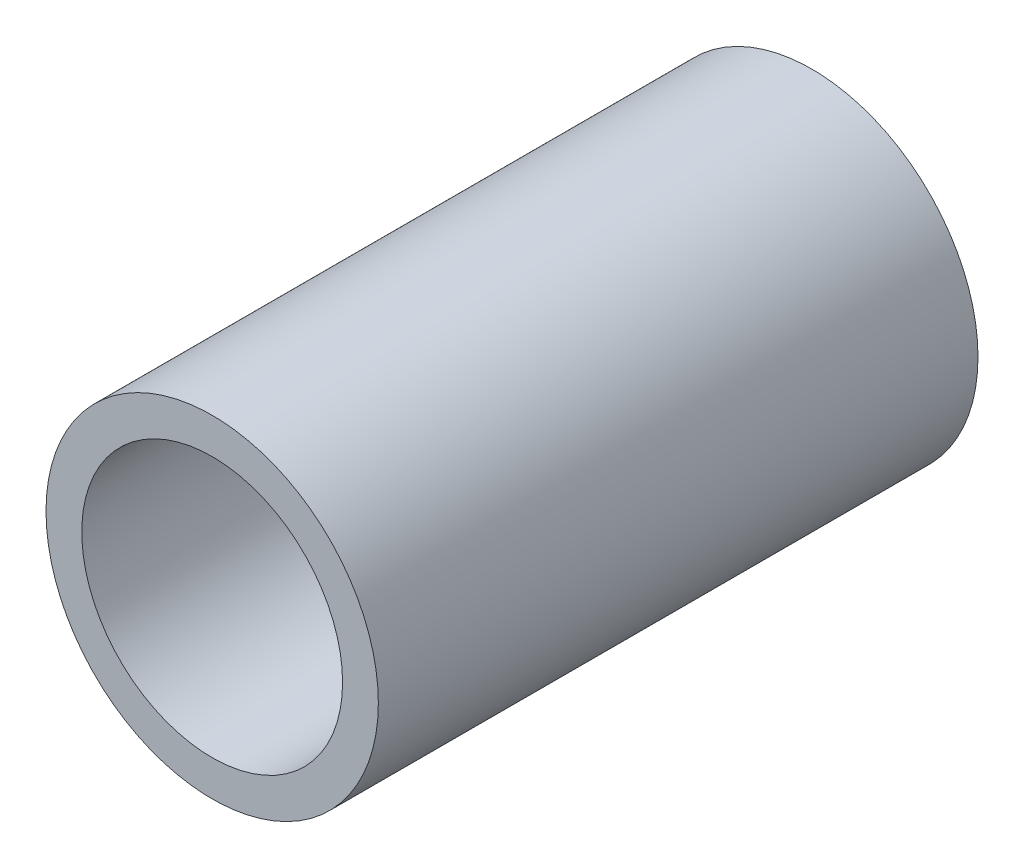
from build123d import *

# Parameters (mm, degrees)
SKETCH3_R                = 13.335
SKETCH3_R_2              = 10.4648
BOSS_EXTRUDE1_DEPTH      = 762
BOSS_EXTRUDE1_DEPTH_BACK = 762
SKETCH4_R                = 13.335
CUT_EXTRUDE2_DEPTH       = 1475.877934


with BuildPart() as part:
    # Sketch3 → Boss-Extrude1 (new body, two sides)
    with BuildSketch(Plane.XY) as boss_extrude1_sk:
        Circle(SKETCH3_R)
        Circle(SKETCH3_R_2, mode=Mode.SUBTRACT)
    extrude(amount=BOSS_EXTRUDE1_DEPTH)
    extrude(boss_extrude1_sk.sketch, amount=-BOSS_EXTRUDE1_DEPTH_BACK)

    # Sketch4 → Cut-Extrude2 (cut)
    with BuildSketch(Plane.XY.offset(762)):
        Circle(SKETCH4_R)
    extrude(amount=-CUT_EXTRUDE2_DEPTH, mode=Mode.SUBTRACT)


solid = part.part
